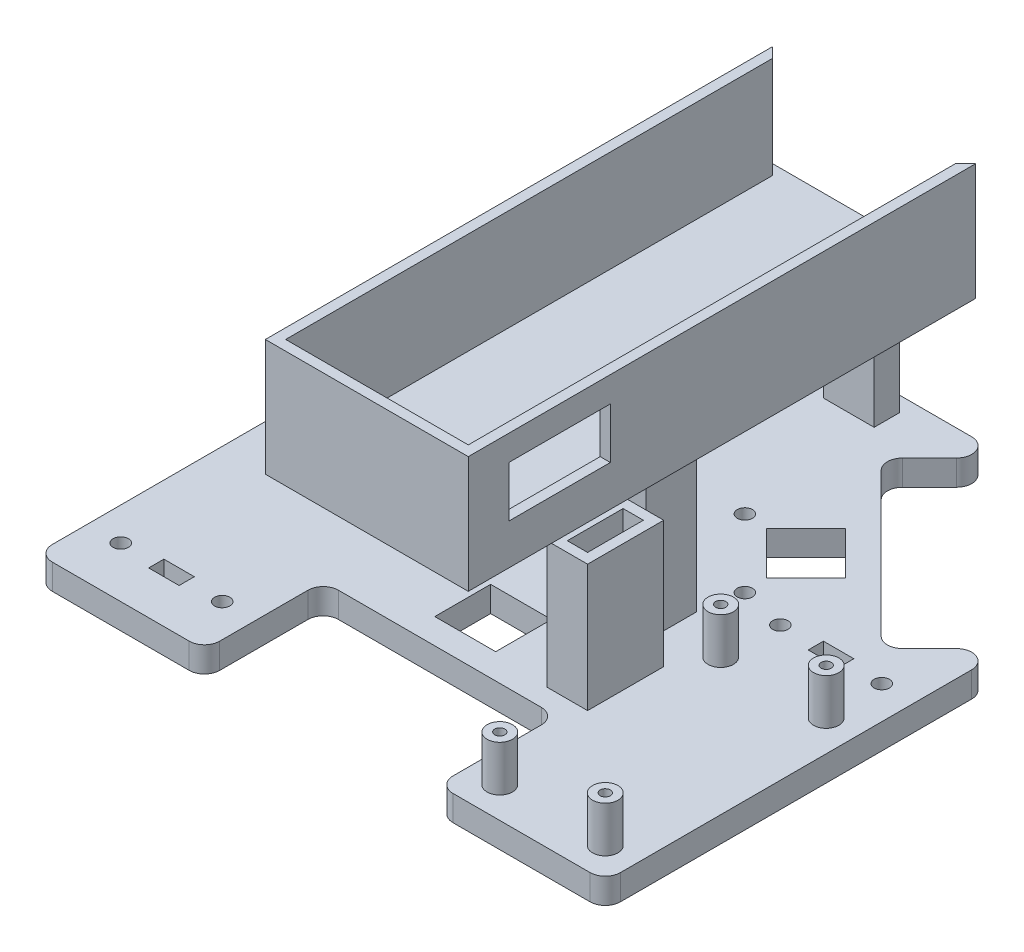
from build123d import *

# Parameters (mm, degrees)
SKETCH1_R               = 1.5
SKETCH1_R_2             = 1
SKETCH1_W               = 12
SKETCH1_H               = 11
BOSS_EXTRUDE1_DEPTH     = 5
FILLET1_R               = 3
BOSS_EXTRUDE2_START     = -60
BOSS_EXTRUDE2_DEPTH     = 7.5
BOSS_EXTRUDE3_START     = -52.5
BOSS_EXTRUDE3_DEPTH     = 2.5
SKETCH4_R               = 2.5
SKETCH4_R_2             = 1
BOSS_EXTRUDE4_DEPTH     = 9
SKETCH5_R               = 1.5
SKETCH5_W               = 6
SKETCH5_H               = 3
CUT_EXTRUDE1_DEPTH      = 81.458933625
CUT_EXTRUDE1_DEPTH_BACK = 81.458933625
SKETCH6_W               = 10
SKETCH6_H               = 5
SKETCH6_W_2             = 5
SKETCH6_H_2             = 10
BOSS_EXTRUDE5_DEPTH     = 27
SKETCH7_W               = 40
SKETCH7_H               = 100
BOSS_EXTRUDE6_DEPTH     = 3
BOSS_EXTRUDE7_DEPTH     = 20
SKETCH9_W               = 20
SKETCH9_H               = 10
CUT_EXTRUDE2_DEPTH      = 2
BOSS_EXTRUDE8_DEPTH     = 3
SKETCH11_W              = 8
SKETCH11_H              = 15
SKETCH11_W_2            = 4
SKETCH11_H_2            = 11
BOSS_EXTRUDE9_DEPTH     = 25
SKETCH12_W              = 10
SKETCH12_H              = 7
CUT_EXTRUDE3_DEPTH      = 4


with BuildPart() as part:
    # Sketch1 → Boss-Extrude1 (new body)
    with BuildSketch(Plane(origin=(0, 0, 0), x_dir=(1, 0, 0), z_dir=(0, 1, 0))):
        Polygon((23, -32.6), (-23, -32.6), (-23, -56), (-56, -56), (-56, 23.473088065), (-43.45370132, 10.926789386), (-10.926789386, 43.45370132), (-23.473088065, 56), (23.473088065, 56), (10.926789386, 43.45370132), (43.45370132, 10.926789386), (56, 23.473088065), (56, -56), (23, -56), align=None)
        with Locations(Location((7.037702089, 20.472730932, 0), (0, 0, 270))):
            Circle(SKETCH1_R, mode=Mode.SUBTRACT)
        with Locations(Location((20.472730932, 7.037702089, 0), (0, 0, 270))):
            Circle(SKETCH1_R, mode=Mode.SUBTRACT)
        with Locations(Location((-9.5, -13.6, 0), (0, 0, 270))):
            Circle(SKETCH1_R, mode=Mode.SUBTRACT)
        with Locations(Location((9.5, -13.6, 0), (0, 0, 270))):
            Circle(SKETCH1_R, mode=Mode.SUBTRACT)
        with Locations(Location((-20.472730932, 7.037702089, 0), (0, 0, 90))):
            Circle(SKETCH1_R, mode=Mode.SUBTRACT)
        with Locations(Location((-7.037702089, 20.472730932, 0), (0, 0, 90))):
            Circle(SKETCH1_R, mode=Mode.SUBTRACT)
        with Locations(Location((29.105, -6.345, 0), (0, 0, 270))):
            Circle(SKETCH1_R_2, mode=Mode.SUBTRACT)
        with Locations(Location((49.895, -6.345, 0), (0, 0, 270))):
            Circle(SKETCH1_R_2, mode=Mode.SUBTRACT)
        with Locations(Location((49.895, -49.895, 0), (0, 0, 270))):
            Circle(SKETCH1_R_2, mode=Mode.SUBTRACT)
        with Locations(Location((29.105, -49.895, 0), (0, 0, 270))):
            Circle(SKETCH1_R_2, mode=Mode.SUBTRACT)
        Polygon((19.41207076, 27.897352134), (11.633896167, 20.119177541), (20.119177541, 11.633896167), (27.897352134, 19.41207076), align=None, mode=Mode.SUBTRACT)
        with Locations((0, -22.1)):
            Rectangle(SKETCH1_W, SKETCH1_H, mode=Mode.SUBTRACT)
        Polygon((-20.119177541, 11.633896167), (-27.897352134, 19.41207076), (-19.41207076, 27.897352134), (-11.633896167, 20.119177541), align=None, mode=Mode.SUBTRACT)
    extrude(amount=BOSS_EXTRUDE1_DEPTH)

    # Fillet1
    fillet1_edges = [part.edges().sort_by_distance(p)[0] for p in [
        (23, 2.5, 32.6),
        (-23, 2.5, 32.6),
        (-23, 2.5, 56),
        (-56, 2.5, 56),
        (-56, 2.5, -23.473088065),
        (-43.45370132, 2.5, -10.926789386),
        (-10.926789386, 2.5, -43.45370132),
        (-23.473088065, 2.5, -56),
        (23.473088065, 2.5, -56),
        (10.926789386, 2.5, -43.45370132),
        (43.45370132, 2.5, -10.926789386),
        (56, 2.5, -23.473088065),
        (56, 2.5, 56),
        (23, 2.5, 56),
    ]]
    fillet(fillet1_edges, radius=FILLET1_R)

    # Sketch3 → Boss-Extrude2 (add)
    with BuildSketch(Plane.XY.offset(56).offset(BOSS_EXTRUDE2_START)):
        with BuildLine():
            Line((-24.7, 11.72249498), (-24.7, 19.2))
            Line((-24.7, 19.2), (-51.2, 19.2))
            Line((-51.2, 19.2), (-51.2, 11.72249498))
            ThreePointArc((-51.2, 11.72249498), (-50.95, 11.1), (-51.2, 10.47750502))
            Line((-51.2, 10.47750502), (-51.2, 5))
            Line((-51.2, 5), (-49.2, 5))
            Line((-49.2, 5), (-49.2, 17.2))
            Line((-49.2, 17.2), (-26.7, 17.2))
            Line((-26.7, 17.2), (-26.7, 5))
            Line((-26.7, 5), (-24.7, 5))
            Line((-24.7, 5), (-24.7, 10.47750502))
            ThreePointArc((-24.7, 10.47750502), (-24.95, 11.1), (-24.7, 11.72249498))
        make_face()
    extrude(amount=BOSS_EXTRUDE2_DEPTH)

    # Sketch3_4 → Boss-Extrude3 (add)
    with BuildSketch(Plane.XY.offset(56).offset(BOSS_EXTRUDE3_START)):
        with BuildLine():
            Line((-21.9, 17.2), (-24.7, 17.2))
            Line((-24.7, 17.2), (-24.7, 11.72249498))
            ThreePointArc((-24.7, 11.72249498), (-23.15, 11.1), (-24.7, 10.47750502))
            Line((-24.7, 10.47750502), (-24.7, 5))
            Line((-24.7, 5), (-21.9, 5))
            Line((-21.9, 5), (-21.9, 17.2))
        make_face()
        with BuildLine():
            Line((-51.2, 11.72249498), (-51.2, 17.2))
            Line((-51.2, 17.2), (-54, 17.2))
            Line((-54, 17.2), (-54, 5))
            Line((-54, 5), (-51.2, 5))
            Line((-51.2, 5), (-51.2, 10.47750502))
            ThreePointArc((-51.2, 10.47750502), (-52.75, 11.1), (-51.2, 11.72249498))
        make_face()
    extrude(amount=-BOSS_EXTRUDE3_DEPTH)

    # Sketch4 → Boss-Extrude4 (add)
    with BuildSketch(Plane(origin=(0, 5, 0), x_dir=(1, 0, 0), z_dir=(0, 1, 0))):
        with Locations(Location((29.105, -6.345, 0), (0, 0, 270))):
            Circle(SKETCH4_R)
        with Locations(Location((29.105, -6.345, 0), (0, 0, 270))):
            Circle(SKETCH4_R_2, mode=Mode.SUBTRACT)
        with Locations(Location((29.105, -49.895, 0), (0, 0, 90))):
            Circle(SKETCH4_R)
        with Locations(Location((29.105, -49.895, 0), (0, 0, 90))):
            Circle(SKETCH4_R_2, mode=Mode.SUBTRACT)
        with Locations(Location((49.895, -49.895, 0), (0, 0, 270))):
            Circle(SKETCH4_R)
        with Locations(Location((49.895, -49.895, 0), (0, 0, 270))):
            Circle(SKETCH4_R_2, mode=Mode.SUBTRACT)
        with Locations(Location((49.895, -6.345, 0), (0, 0, 90))):
            Circle(SKETCH4_R)
        with Locations(Location((49.895, -6.345, 0), (0, 0, 90))):
            Circle(SKETCH4_R_2, mode=Mode.SUBTRACT)
    extrude(amount=BOSS_EXTRUDE4_DEPTH)

    # Sketch5 → Cut-Extrude1 (cut, two sides)
    with BuildSketch(Plane(origin=(0, 5, 0), x_dir=(1, 0, 0), z_dir=(0, 1, 0))) as cut_extrude1_sk:
        with Locations(Location((-29.5, -46, 0), (0, 0, 270))):
            Circle(SKETCH5_R)
        with Locations(Location((-49.5, -46, 0), (0, 0, 270))):
            Circle(SKETCH5_R)
        with Locations(Location((29.5, 5, 0), (0, 0, 270))):
            Circle(SKETCH5_R)
        with Locations(Location((49.5, 5, 0), (0, 0, 270))):
            Circle(SKETCH5_R)
        with Locations((-39.5, -46)):
            Rectangle(SKETCH5_W, SKETCH5_H)
        with Locations((39.5, 5)):
            Rectangle(SKETCH5_W, SKETCH5_H)
    extrude(amount=CUT_EXTRUDE1_DEPTH, mode=Mode.SUBTRACT)
    extrude(cut_extrude1_sk.sketch, amount=-CUT_EXTRUDE1_DEPTH_BACK, mode=Mode.SUBTRACT)

    # Sketch6 → Boss-Extrude5 (add)
    with BuildSketch(Plane(origin=(0, 5, 0), x_dir=(1, 0, 0), z_dir=(0, 1, 0))):
        with Locations((0, 50.5)):
            Rectangle(SKETCH6_W, SKETCH6_H)
        with Locations((-16.5, -6)):
            Rectangle(SKETCH6_W_2, SKETCH6_H_2)
        with Locations((16.5, -6)):
            Rectangle(SKETCH6_W_2, SKETCH6_H_2)
    extrude(amount=BOSS_EXTRUDE5_DEPTH)

    # Sketch7 → Boss-Extrude6 (add)
    with BuildSketch(Plane(origin=(0, 32, 0), x_dir=(1, 0, 0), z_dir=(0, 1, 0))):
        with Locations((0, 3)):
            Rectangle(SKETCH7_W, SKETCH7_H)
    extrude(amount=BOSS_EXTRUDE6_DEPTH)

    # Sketch8 → Boss-Extrude7 (add)
    with BuildSketch(Plane(origin=(0, 35, 0), x_dir=(1, 0, 0), z_dir=(0, 1, 0))):
        Polygon((-18, 51), (-18, -45), (18, -45), (18, 51), (20, 53), (20, -47), (-20, -47), (-20, 53), align=None)
    extrude(amount=BOSS_EXTRUDE7_DEPTH)

    # Sketch9 → Cut-Extrude2 (cut)
    with BuildSketch(Plane(origin=(20, 0, 0), x_dir=(0, 0, -1), z_dir=(1, 0, 0))):
        with Locations((-29, 45)):
            Rectangle(SKETCH9_W, SKETCH9_H)
    extrude(amount=-CUT_EXTRUDE2_DEPTH, mode=Mode.SUBTRACT)

    # Sketch10 → Boss-Extrude8 (add)
    with BuildSketch(Plane.XY):
        Polygon((-5.25, 5), (-5.25, 8.5), (5.25, 8.5), (5.25, 5), (4.25, 5), (4.25, 7.5), (-4.25, 7.5), (-4.25, 5), align=None)
    extrude(amount=-BOSS_EXTRUDE8_DEPTH)

    # Sketch11 → Boss-Extrude9 (add)
    with BuildSketch(Plane(origin=(0, 5, 0), x_dir=(1, 0, 0), z_dir=(0, 1, 0))):
        with Locations((21.115986736, -21.1)):
            Rectangle(SKETCH11_W, SKETCH11_H)
        with Locations((21.115986736, -21.1)):
            Rectangle(SKETCH11_W_2, SKETCH11_H_2, mode=Mode.SUBTRACT)
    extrude(amount=BOSS_EXTRUDE9_DEPTH)

    # Sketch12 → Cut-Extrude3 (cut)
    with BuildSketch(Plane.ZY.offset(-17.115986736)):
        with Locations((21.1, 8.5)):
            Rectangle(SKETCH12_W, SKETCH12_H)
    extrude(amount=-CUT_EXTRUDE3_DEPTH, mode=Mode.SUBTRACT)


solid = part.part
